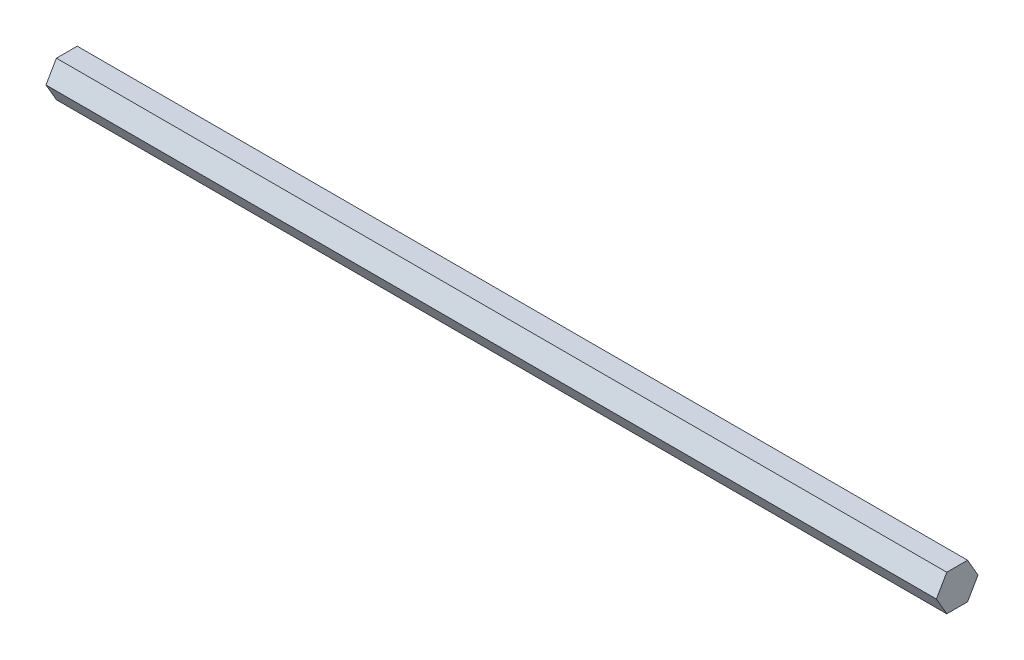
from build123d import *

# Parameters (mm, degrees)
BOSS_EXTRUDE1_DEPTH = 313.7


with BuildPart() as part:
    # Sketch1 → Boss-Extrude1 (new body)
    with BuildSketch(Plane(origin=(0, 0, 0), x_dir=(0, 0, -1), z_dir=(1, 0, 0))):
        Polygon((7.332348419, 0), (3.666174209, 6.35), (-3.666174209, 6.35), (-7.332348419, 0), (-3.666174209, -6.35), (3.666174209, -6.35), align=None)
    extrude(amount=BOSS_EXTRUDE1_DEPTH)


solid = part.part
